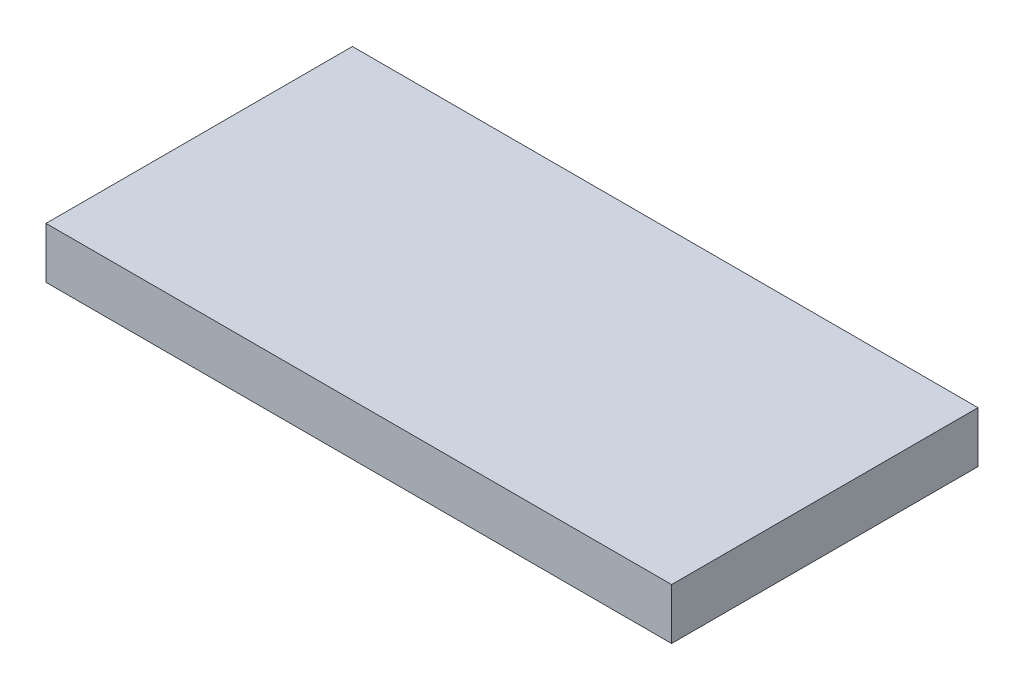
from build123d import *

# Parameters (mm, degrees)
SKETCH1_W           = 98
SKETCH1_H           = 48
BOSS_EXTRUDE1_DEPTH = 8


with BuildPart() as part:
    # Sketch1 → Boss-Extrude1 (new body)
    with BuildSketch(Plane(origin=(0, 0, 0), x_dir=(1, 0, 0), z_dir=(0, 1, 0))):
        Rectangle(SKETCH1_W, SKETCH1_H)
    extrude(amount=BOSS_EXTRUDE1_DEPTH)


solid = part.part
